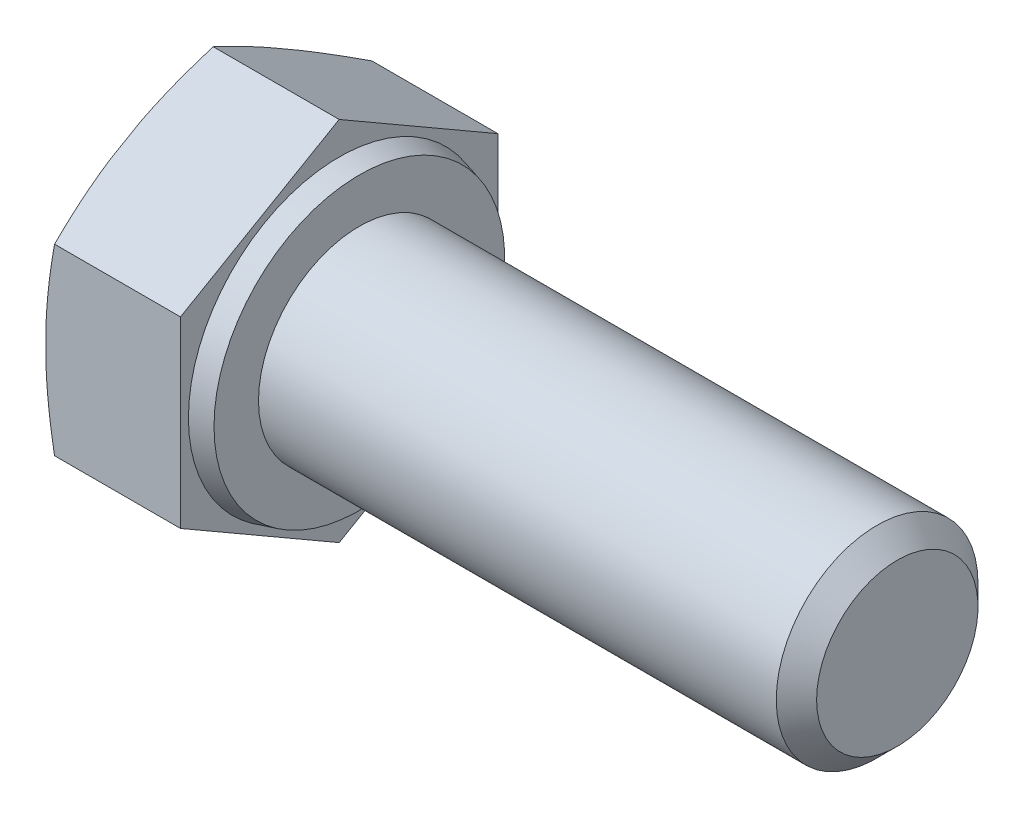
from build123d import *

# Parameters (mm, degrees)
SKETCH_2_OUTSIDE_W  = 18.046
SKETCH_2_OUTSIDE_H  = 18.046
CUT_EXTRUDE_1_DEPTH = 22.994658442
CHAMFER_1_SIZE      = 0.6


with BuildPart() as part:
    # Эскиз1 → Повернуть1 (revolve)
    with BuildSketch(Plane.XY, mode=Mode.PRIVATE) as revolve_1_sk:
        Polygon((-4, 0), (-4, 5.45), (0, 5.45), (0, 4.483974596), (0.6, 4.323205081), (0.6, 3), (16.6, 3), (16.6, 0), align=None)
    revolve(revolve_1_sk.sketch.rotate(Axis((-1000, 0, 0), (1, 0, 0)), 90), axis=Axis((-1000, 0, 0), (1, 0, 0)))

    # Эскиз2 outside → Вырез-Вытянуть1 (cut, through all)
    with BuildSketch(Plane.ZY.offset(4)):
        Rectangle(SKETCH_2_OUTSIDE_W, SKETCH_2_OUTSIDE_H)
        Polygon((0, -5.45), (4.719838451, -2.725), (4.719838451, 2.725), (0, 5.45), (-4.719838451, 2.725), (-4.719838451, -2.725), align=None, mode=Mode.SUBTRACT)
    extrude(amount=-CUT_EXTRUDE_1_DEPTH, mode=Mode.SUBTRACT)

    # Эскиз4 → Вырез-Повернуть1 (revolve, cut)
    with BuildSketch(Plane.XY):
        Polygon((-4, 4.75), (-3.745220836, 5.45), (-4, 5.45), align=None)
    revolve(axis=Axis((-1000, 0, 0), (1, 0, 0)), mode=Mode.SUBTRACT)

    # Фаска1
    chamfer_1_edges = [part.edges().sort_by_distance(p)[0] for p in [
        (16.6, 0, -3),
    ]]
    chamfer(chamfer_1_edges, length=CHAMFER_1_SIZE)


solid = part.part
